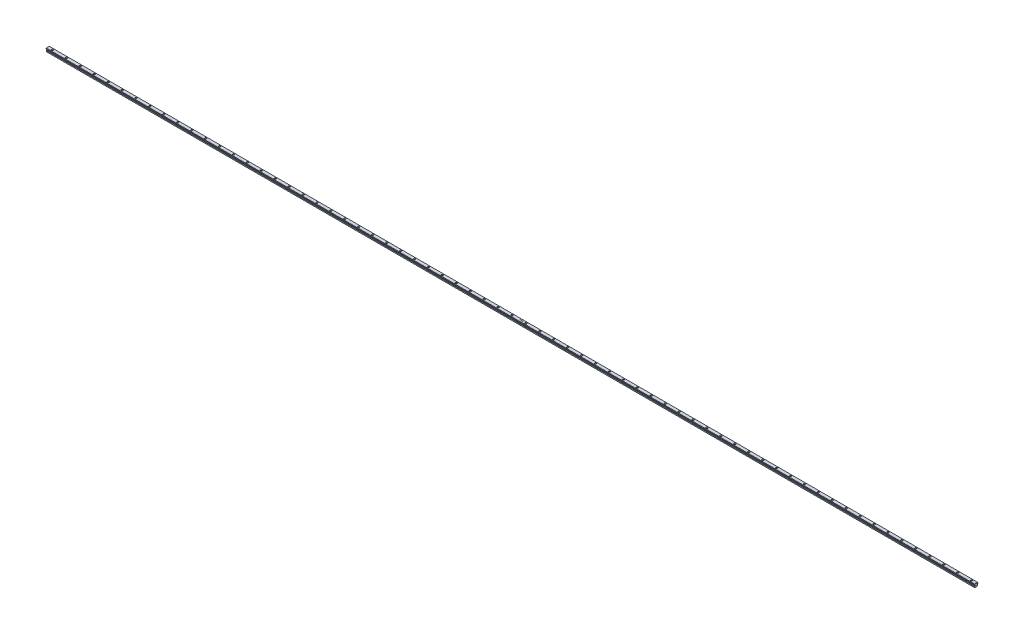
from build123d import *

# Parameters (mm, degrees)
BOSS_EXTRUDE1_DEPTH = 2000
SKETCH2_R           = 3.75
CUT_EXTRUDE1_DEPTH  = 5.3
SKETCH3_R           = 2.25
CUT_EXTRUDE2_DEPTH  = 9.18856406
CHAMFER1_SIZE       = 1
LPATTERN1_COUNT     = 67
LPATTERN1_PITCH     = 60
CUT_EXTRUDE3_DEPTH  = 2


with BuildPart() as part:
    # Sketch1 → Boss-Extrude1 (new body, symmetric)
    with BuildSketch(Plane(origin=(0, 0, 0), x_dir=(0, 0, -1), z_dir=(1, 0, 0))):
        Polygon((-6.5, 31.490611299), (6.5, 31.490611299), (7.758650071, 30.231961228), (7.758650071, 28.231961228), (4.774659454, 26.327387785), (4.774659454, 24.327387785), (6.5, 22.602047239), (6.5, 18.002047239), (-6.5, 18.002047239), (-6.5, 22.602047239), (-4.774659454, 24.327387785), (-4.774659454, 26.327387785), (-7.758650071, 28.231961228), (-7.758650071, 30.231961228), align=None)
    extrude(amount=BOSS_EXTRUDE1_DEPTH, both=True)

    # Sketch2 → Cut-Extrude1 (cut)
    with BuildSketch(Plane(origin=(0, 31.490611299, 0), x_dir=(1, 0, 0), z_dir=(0, 1, 0))):
        with Locations(Location((1980, 0, 0), (0, 0, 270))):  # turned: the seam where the file's is
            Circle(SKETCH2_R)
    cut_extrude1 = extrude(amount=-CUT_EXTRUDE1_DEPTH, mode=Mode.SUBTRACT)

    # Sketch3 → Cut-Extrude2 (cut, through all)
    with BuildSketch(Plane(origin=(0, 26.190611299, 0), x_dir=(1, 0, 0), z_dir=(0, 1, 0))):
        with Locations(Location((1980, 0, 0), (0, 0, 270))):  # turned: the seam where the file's is
            Circle(SKETCH3_R)
    cut_extrude2 = extrude(amount=-CUT_EXTRUDE2_DEPTH, mode=Mode.SUBTRACT)

    # Chamfer1
    chamfer1_edges = [part.edges().sort_by_distance(p)[0] for p in [
        (2000, 31.490611299, 0),
    ]]
    chamfer(chamfer1_edges, length=CHAMFER1_SIZE)

    # LPattern1: Cut-Extrude1, Cut-Extrude2 ×67
    with Locations(*[(-i * LPATTERN1_PITCH, 0, 0) for i in range(1, LPATTERN1_COUNT)]):
        add(cut_extrude1, mode=Mode.SUBTRACT)
        add(cut_extrude2, mode=Mode.SUBTRACT)

    # Sketch4 → Cut-Extrude3 (cut)
    with BuildSketch(Plane(origin=(0, 31.490611299, 0), x_dir=(1, 0, 0), z_dir=(0, 1, 0))):
        with BuildLine():
            Line((26.185845324, -0.037615656), (26.481718721, 0.139768158))
            add(Edge.make_bspline(
                [(26.481718721, 0.139768158), (26.509236958, 0.093703773), (26.561960839, 0.005446189), (26.649912198, -0.113811851), (26.741045109, -0.215174008), (26.836034443, -0.298050616), (26.934300391, -0.363299502), (27.036484445, -0.409501734), (27.142242255, -0.43831771), (27.214216077, -0.441817796), (27.250148208, -0.443565175)],
                knots=[0, 0, 0, 0, 1.272034388, 2.437168799, 3.508375237, 4.49857839, 5.41946034, 6.295179144, 7.148887113, 8, 8, 8, 8], degree=3))
            add(Edge.make_bspline(
                [(27.250148208, -0.443565175), (27.280835069, -0.442710503), (27.341671842, -0.441016113), (27.431234085, -0.424735311), (27.518215887, -0.399723182), (27.600824525, -0.36390225), (27.677920139, -0.320563765), (27.745526835, -0.268217587), (27.803972948, -0.209611381), (27.851782062, -0.144228727), (27.888462098, -0.073911578), (27.916654166, -0.001735627), (27.93229924, 0.073432942), (27.934655993, 0.124043404), (27.935845324, 0.149583863)],
                knots=[0, 0, 0, 0, 1.095163259, 2.171163733, 3.241058638, 4.321873601, 5.38011039, 6.391990106, 7.366004449, 8.327778327, 9.272591725, 10.192022065, 11.087607919, 12, 12, 12, 12], degree=3))
            add(Edge.make_bspline(
                [(27.935845324, 0.149583863), (27.934371013, 0.178724713), (27.931373955, 0.237963802), (27.906042475, 0.325363455), (27.866193228, 0.411856025), (27.829430584, 0.46535729), (27.810344522, 0.493133542)],
                knots=[0, 0, 0, 0, 0.938893495, 1.908633276, 2.914225137, 4, 4, 4, 4], degree=3))
            add(Edge.make_bspline(
                [(27.810344522, 0.493133542), (27.794673908, 0.513180366), (27.761775414, 0.555266165), (27.705217901, 0.6179114), (27.638851787, 0.682529819), (27.564948232, 0.751588876), (27.480815143, 0.821876673), (27.389087629, 0.896744951), (27.28742377, 0.973346528), (27.216124273, 1.024719093), (27.179334907, 1.051226491)],
                knots=[0, 0, 0, 0, 0.722233717, 1.516239348, 2.393582979, 3.351407094, 4.387010283, 5.505090956, 6.712668013, 8, 8, 8, 8], degree=3))
            add(Edge.make_bspline(
                [(27.179334907, 1.051226491), (27.142510911, 1.077455079), (27.072106234, 1.127602141), (26.973647652, 1.202026425), (26.885603189, 1.270070295), (26.808364172, 1.332374307), (26.741964576, 1.388946911), (26.685881165, 1.439244851), (26.641542607, 1.484628411), (26.616887027, 1.514069753), (26.605817279, 1.52728819)],
                knots=[0, 0, 0, 0, 1.452282411, 2.77665338, 3.964542531, 5.026858415, 5.96415736, 6.766646006, 7.446254459, 8, 8, 8, 8], degree=3))
            add(Edge.make_bspline(
                [(26.605817279, 1.52728819), (26.590344734, 1.547889227), (26.559915897, 1.588403931), (26.519749891, 1.651728788), (26.485610729, 1.716552054), (26.458848396, 1.783047918), (26.436312178, 1.850282847), (26.421154247, 1.919134093), (26.41166285, 1.989292711), (26.410690863, 2.036506212), (26.410204298, 2.060140754)],
                knots=[0, 0, 0, 0, 1.068054152, 2.10047183, 3.106115577, 4.101338837, 5.06977816, 6.043150881, 7.020423561, 8, 8, 8, 8], degree=3))
            add(Edge.make_bspline(
                [(26.410204298, 2.060140754), (26.411509507, 2.097170529), (26.414092027, 2.170438592), (26.435932544, 2.277469423), (26.470405438, 2.37965584), (26.518700326, 2.475986174), (26.580957679, 2.563952155), (26.653003653, 2.644565642), (26.738815139, 2.712334224), (26.832967763, 2.771546282), (26.936024135, 2.817892207), (27.044015038, 2.852853188), (27.15711211, 2.872662445), (27.233715245, 2.87550521), (27.272584106, 2.876947645)],
                knots=[0, 0, 0, 0, 1.005424448, 1.989358655, 2.955360095, 3.929531133, 4.905563448, 5.876582895, 6.856512386, 7.866279853, 8.892233794, 9.918561126, 10.94386622, 12, 12, 12, 12], degree=3))
            add(Edge.make_bspline(
                [(27.272584106, 2.876947645), (27.313828206, 2.875525093), (27.395849558, 2.872696092), (27.516498773, 2.848098561), (27.63265949, 2.807397889), (27.726102755, 2.761209231), (27.799235516, 2.715077816), (27.855008249, 2.673057991), (27.9115257, 2.624682883), (27.969243754, 2.569823637), (28.027184414, 2.507976885), (28.086207866, 2.439566197), (28.146452135, 2.365009641), (28.185207995, 2.31178514), (28.205076093, 2.284499728)],
                knots=[0, 0, 0, 0, 1.286793592, 2.559021753, 3.825965368, 5.121522368, 5.803751409, 6.523245864, 7.299691795, 8.125521123, 9.008227632, 9.944561021, 10.946284179, 12, 12, 12, 12], degree=3))
            Line((28.205076093, 2.284499728), (27.921121766, 2.069255337))
            add(Edge.make_bspline(
                [(27.921121766, 2.069255337), (27.903975834, 2.091344028), (27.870956776, 2.133881681), (27.82082729, 2.193452997), (27.773578642, 2.247869476), (27.727028242, 2.295134604), (27.68363461, 2.337836737), (27.641517568, 2.374396494), (27.601283217, 2.40517209), (27.550566306, 2.43801565), (27.486848588, 2.470572153), (27.406864052, 2.498121231), (27.323277777, 2.514676293), (27.266348145, 2.516865181), (27.237528016, 2.517973286)],
                knots=[0, 0, 0, 0, 1.181633172, 2.275549214, 3.290209073, 4.226197932, 5.078386478, 5.862611352, 6.581680152, 7.217281963, 8.414376989, 9.595101626, 10.782541182, 12, 12, 12, 12], degree=3))
            add(Edge.make_bspline(
                [(27.237528016, 2.517973286), (27.201371494, 2.516761586), (27.131647046, 2.514424937), (27.03265681, 2.488904952), (26.943562885, 2.448723091), (26.86701032, 2.392408113), (26.803273343, 2.325687121), (26.757167884, 2.248908265), (26.72941772, 2.164125863), (26.72603144, 2.104984206), (26.724306862, 2.074864312)],
                knots=[0, 0, 0, 0, 1.14458467, 2.207223713, 3.21896685, 4.227309161, 5.202851033, 6.127160689, 7.046193047, 8, 8, 8, 8], degree=3))
            add(Edge.make_bspline(
                [(26.724306862, 2.074864312), (26.724699989, 2.056112833), (26.725486885, 2.018579214), (26.736461683, 1.963127792), (26.750561012, 1.907816452), (26.772903643, 1.85289387), (26.803748947, 1.79739951), (26.844254123, 1.740377773), (26.895267435, 1.681326064), (26.934344447, 1.64291869), (26.954975933, 1.622640754)],
                knots=[0, 0, 0, 0, 0.858281714, 1.717966888, 2.583508476, 3.4729293, 4.427298488, 5.488583878, 6.674047936, 8, 8, 8, 8], degree=3))
            add(Edge.make_bspline(
                [(26.954975933, 1.622640754), (26.962637305, 1.615803728), (26.980838972, 1.59956052), (27.014114898, 1.572968239), (27.058057696, 1.540165467), (27.111519897, 1.49957815), (27.175487259, 1.452496688), (27.249966815, 1.399523076), (27.334128348, 1.338937617), (27.393850264, 1.296580077), (27.425428657, 1.274183222)],
                knots=[0, 0, 0, 0, 0.420754252, 0.999615792, 1.744751191, 2.668019286, 3.750313428, 4.999500688, 6.413464383, 8, 8, 8, 8], degree=3))
            add(Edge.make_bspline(
                [(27.425428657, 1.274183222), (27.46341457, 1.246541862), (27.536969027, 1.193018201), (27.641626607, 1.112602521), (27.736520415, 1.033954752), (27.821983618, 0.957577145), (27.898860527, 0.884049052), (27.966298247, 0.812485872), (28.024983928, 0.743400299), (28.088163146, 0.654827723), (28.152720966, 0.546046639), (28.208162473, 0.4127684), (28.243120821, 0.27897208), (28.247692336, 0.189045243), (28.249947888, 0.14467601)],
                knots=[0, 0, 0, 0, 1.163667725, 2.253281268, 3.268753668, 4.215851969, 5.092017293, 5.902905408, 6.650798638, 7.335211899, 8.59617414, 9.77448103, 10.901945474, 12, 12, 12, 12], degree=3))
            add(Edge.make_bspline(
                [(28.249947888, 0.14467601), (28.24929075, 0.113297645), (28.247989235, 0.051150262), (28.233028321, -0.040104815), (28.211108656, -0.128735685), (28.178071422, -0.213646797), (28.137748263, -0.29639156), (28.086582016, -0.37479946), (28.027274331, -0.450605859), (27.959240566, -0.52178935), (27.884794664, -0.587135546), (27.806110969, -0.645264608), (27.723060696, -0.693732931), (27.636094379, -0.733283773), (27.545192043, -0.764217291), (27.450384259, -0.78663016), (27.351514748, -0.800385871), (27.284314266, -0.801813632), (27.250148208, -0.802539534)],
                knots=[0, 0, 0, 0, 0.983748083, 1.948392443, 2.894712957, 3.844097841, 4.80183111, 5.778335162, 6.776009319, 7.81870978, 8.863265674, 9.881300176, 10.883814829, 11.87499822, 12.874611388, 13.892143829, 14.928324115, 16, 16, 16, 16], degree=3))
            add(Edge.make_bspline(
                [(27.250148208, -0.802539534), (27.223712865, -0.802028353), (27.171175105, -0.801012427), (27.093465623, -0.792031147), (27.017326034, -0.779324043), (26.943711752, -0.759149973), (26.871674341, -0.734672996), (26.801527106, -0.704534664), (26.733236052, -0.668417462), (26.666418469, -0.627122438), (26.601244295, -0.579064693), (26.538324827, -0.523091197), (26.475595641, -0.460745692), (26.414908245, -0.390335128), (26.355035101, -0.312997046), (26.297156691, -0.228007862), (26.240074973, -0.135830508), (26.204259506, -0.070965423), (26.185845324, -0.037615656)],
                knots=[0, 0, 0, 0, 0.915332311, 1.819136955, 2.706846663, 3.586547465, 4.459518054, 5.340707479, 6.227863349, 7.133153174, 8.059268498, 9.028702269, 10.047606654, 11.120612155, 12.245963614, 13.433783089, 14.680604001, 16, 16, 16, 16], degree=3))
        make_face()
        Polygon((28.967896606, 2.787204055), (29.28199917, 2.787204055), (29.28199917, 1.351306619), (31.076870965, 1.351306619), (31.076870965, 2.787204055), (31.390973529, 2.787204055), (31.390973529, -0.712795945), (31.076870965, -0.712795945), (31.076870965, 0.99233226), (29.28199917, 0.99233226), (29.28199917, -0.712795945), (28.967896606, -0.712795945), align=None)
        Polygon((32.288409426, -0.712795945), (32.288409426, 2.787204055), (32.354314875, 2.787204055), (34.666614554, 0.032496523), (34.666614554, 2.787204055), (34.980717119, 2.787204055), (34.980717119, -0.712795945), (34.909202696, -0.712795945), (32.60251199, 2.035601491), (32.60251199, -0.712795945), align=None)
        Polygon((37.654094522, 2.787204055), (38.301229939, 2.787204055), (38.301229939, -0.712795945), (37.987127375, -0.712795945), (37.987127375, 2.428229696), (37.448665837, 2.428229696), align=None)
        with BuildLine():
            Line((41.801229939, 2.787204055), (41.801229939, 2.428229696))
            Line((41.801229939, 2.428229696), (40.610725131, 2.428229696))
            Line((40.610725131, 2.428229696), (40.422123369, 1.50765678))
            add(Edge.make_bspline(
                [(40.422123369, 1.50765678), (40.459179243, 1.517887051), (40.530969139, 1.537706585), (40.636929, 1.559712355), (40.737521203, 1.5729778), (40.802796574, 1.57478911), (40.834382984, 1.575665594)],
                knots=[0, 0, 0, 0, 1.100273476, 2.13160584, 3.095893838, 4, 4, 4, 4], degree=3))
            add(Edge.make_bspline(
                [(40.834382984, 1.575665594), (40.873466724, 1.574819658), (40.950315121, 1.573156337), (41.062754068, 1.557184488), (41.170086961, 1.532044573), (41.272089331, 1.496924051), (41.368949882, 1.452014318), (41.459777444, 1.395914378), (41.545935356, 1.330381047), (41.62587795, 1.255036035), (41.698402259, 1.172114418), (41.762168248, 1.082956547), (41.816330839, 0.988428885), (41.859891593, 0.887628276), (41.894675928, 0.781669123), (41.917827923, 0.66943654), (41.933244632, 0.55198842), (41.934967018, 0.47168385), (41.935845324, 0.430733703)],
                knots=[0, 0, 0, 0, 1.052922333, 2.070308379, 3.05430497, 4.020497103, 4.973039431, 5.925935799, 6.892292201, 7.88610001, 8.88166317, 9.857072816, 10.836096531, 11.812156883, 12.81219415, 13.836441305, 14.89672472, 16, 16, 16, 16], degree=3))
            add(Edge.make_bspline(
                [(41.935845324, 0.430733703), (41.935180248, 0.402211482), (41.933859086, 0.345552495), (41.927140498, 0.261408294), (41.914204782, 0.179045461), (41.896837058, 0.098453069), (41.87429464, 0.019783697), (41.847005586, -0.057187831), (41.813609559, -0.131982438), (41.776978183, -0.205307833), (41.735731705, -0.27550634), (41.689953198, -0.341155326), (41.641587707, -0.403239608), (41.589546321, -0.461093341), (41.533345326, -0.514336359), (41.473665359, -0.56328464), (41.41098264, -0.608765971), (41.344327398, -0.648934166), (41.275184915, -0.685897122), (41.202556698, -0.716220659), (41.128095997, -0.743331187), (41.050731122, -0.764940715), (40.970637309, -0.78187327), (40.887682534, -0.79337387), (40.802301864, -0.801750308), (40.744426851, -0.802274665), (40.715192279, -0.802539534)],
                knots=[0, 0, 0, 0, 1.056347294, 2.098418968, 3.122841568, 4.141288669, 5.149314143, 6.15115421, 7.162517403, 8.180376062, 9.185164535, 10.17417709, 11.141909838, 12.097768115, 13.052685741, 14.0056014, 14.954263652, 15.917497458, 16.885230207, 17.854509472, 18.828990115, 19.81800267, 20.826176721, 21.857883937, 22.917946725, 24, 24, 24, 24], degree=3))
            add(Edge.make_bspline(
                [(40.715192279, -0.802539534), (40.680318098, -0.801848696), (40.611707267, -0.800489554), (40.5111867, -0.786271069), (40.414472095, -0.765907153), (40.322341994, -0.735270883), (40.23397073, -0.696883588), (40.150548012, -0.648367417), (40.069942236, -0.593388313), (39.995430199, -0.52850796), (39.926274086, -0.457592278), (39.864367577, -0.380634637), (39.809234, -0.298905195), (39.761756253, -0.212007041), (39.721258232, -0.12016851), (39.689443244, -0.023045509), (39.663764889, 0.078854495), (39.652901468, 0.149008006), (39.647383785, 0.184639953)],
                knots=[0, 0, 0, 0, 1.0467383, 2.05933395, 3.04377827, 4.011590433, 4.970194871, 5.932262533, 6.905835911, 7.896367577, 8.894135286, 9.877477877, 10.858688626, 11.851381753, 12.8477658, 13.868841284, 14.917554742, 16, 16, 16, 16], degree=3))
            Line((39.647383785, 0.184639953), (39.961486349, 0.184639953))
            add(Edge.make_bspline(
                [(39.961486349, 0.184639953), (39.969214907, 0.1512635), (39.984069623, 0.087112105), (40.016675372, -0.003019236), (40.056541247, -0.08333846), (40.103945596, -0.154908043), (40.160495626, -0.21731704), (40.225025055, -0.272934102), (40.297372778, -0.323109231), (40.377766008, -0.364931999), (40.462579087, -0.400600752), (40.551346297, -0.424352447), (40.641650644, -0.44105334), (40.702729014, -0.442725101), (40.733421446, -0.443565175)],
                knots=[0, 0, 0, 0, 1.136247022, 2.183929868, 3.172523383, 4.106158343, 5.02341133, 5.958108904, 6.928429099, 7.938127109, 8.96079061, 9.975095812, 10.982467395, 12, 12, 12, 12], degree=3))
            add(Edge.make_bspline(
                [(40.733421446, -0.443565175), (40.76337989, -0.442744398), (40.822368312, -0.441128279), (40.909179699, -0.428689267), (40.992992573, -0.409531696), (41.07297993, -0.380861841), (41.150541469, -0.346017122), (41.22371524, -0.301302047), (41.294618117, -0.249842028), (41.36104625, -0.190885398), (41.4218857, -0.125915703), (41.475641821, -0.05643831), (41.520418734, 0.017678537), (41.558152843, 0.095151689), (41.586806142, 0.176830247), (41.607247123, 0.262331422), (41.619250182, 0.351866402), (41.620901362, 0.412935712), (41.62174276, 0.444055017)],
                knots=[0, 0, 0, 0, 1.027316725, 2.022795036, 3.002884548, 3.971462791, 4.93288096, 5.914575861, 6.907176829, 7.935150275, 8.956128384, 9.956726525, 10.942570165, 11.921478529, 12.907843606, 13.90538589, 14.932640048, 16, 16, 16, 16], degree=3))
            add(Edge.make_bspline(
                [(41.62174276, 0.444055017), (41.62108428, 0.472130768), (41.6197954, 0.527085057), (41.60926483, 0.607484264), (41.590947858, 0.683557306), (41.565523978, 0.75567154), (41.53324447, 0.823894983), (41.493798158, 0.888298043), (41.44644476, 0.948031876), (41.392352871, 1.00312443), (41.33309483, 1.053969304), (41.267651088, 1.097313391), (41.197391161, 1.133777309), (41.123161561, 1.165245307), (41.043196663, 1.187846052), (40.95908003, 1.204813938), (40.869903322, 1.2146293), (40.808932634, 1.215991189), (40.777592119, 1.216691235)],
                knots=[0, 0, 0, 0, 1.045622112, 2.046656509, 3.013763289, 3.955457236, 4.890082067, 5.820317437, 6.762574623, 7.722996705, 8.69280354, 9.665887285, 10.63943826, 11.638615906, 12.663482002, 13.728887084, 14.832589034, 16, 16, 16, 16], degree=3))
            add(Edge.make_bspline(
                [(40.777592119, 1.216691235), (40.75046319, 1.216110644), (40.694448834, 1.21491187), (40.608526008, 1.206085373), (40.518234285, 1.191846079), (40.423919789, 1.172259831), (40.325299281, 1.146628755), (40.22258088, 1.115914254), (40.115548614, 1.079192255), (40.043430889, 1.051460042), (40.006358144, 1.037204055)],
                knots=[0, 0, 0, 0, 0.817624296, 1.688186739, 2.600797293, 3.572016777, 4.590301741, 5.671205678, 6.80286297, 8, 8, 8, 8], degree=3))
            Line((40.006358144, 1.037204055), (40.365332503, 2.787204055))
            Line((40.365332503, 2.787204055), (41.801229939, 2.787204055))
        make_face()
        Polygon((45.390973529, 2.787204055), (47.006358144, -0.712795945), (46.66491183, -0.712795945), (46.147483946, 0.408998927), (44.560845324, 0.408998927), (44.028693881, -0.712795945), (43.685845324, -0.712795945), (45.346101734, 2.787204055), align=None)
        Polygon((45.365032022, 2.105012549), (44.73121792, 0.767973286), (45.982019202, 0.767973286), align=None, mode=Mode.SUBTRACT)
    extrude(amount=-CUT_EXTRUDE3_DEPTH, mode=Mode.SUBTRACT)


solid = part.part
